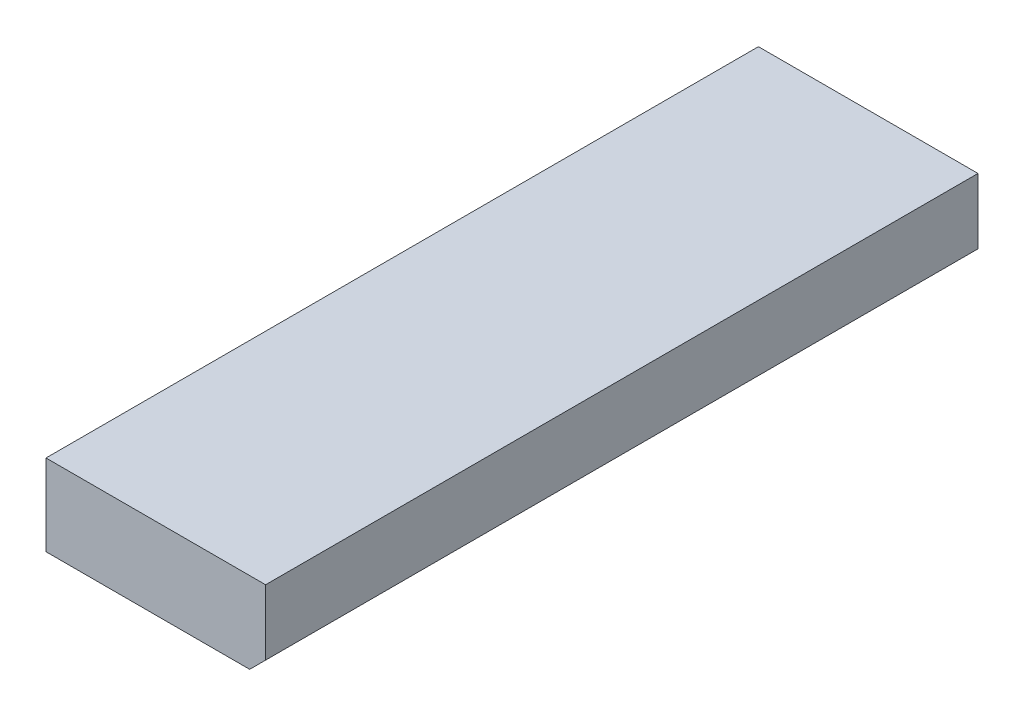
from build123d import *

# Parameters (mm, degrees)
BOSS_EXTRUDE1_DEPTH = 2.138


with BuildPart() as part:
    # Sketch1 → Boss-Extrude1 (new body)
    with BuildSketch(Plane.XY):
        Polygon((0, 0), (0.61123, 0), (0.659, 0.04777), (0.659, 0.24375), (0, 0.24375), align=None)
    extrude(amount=BOSS_EXTRUDE1_DEPTH)


solid = part.part
